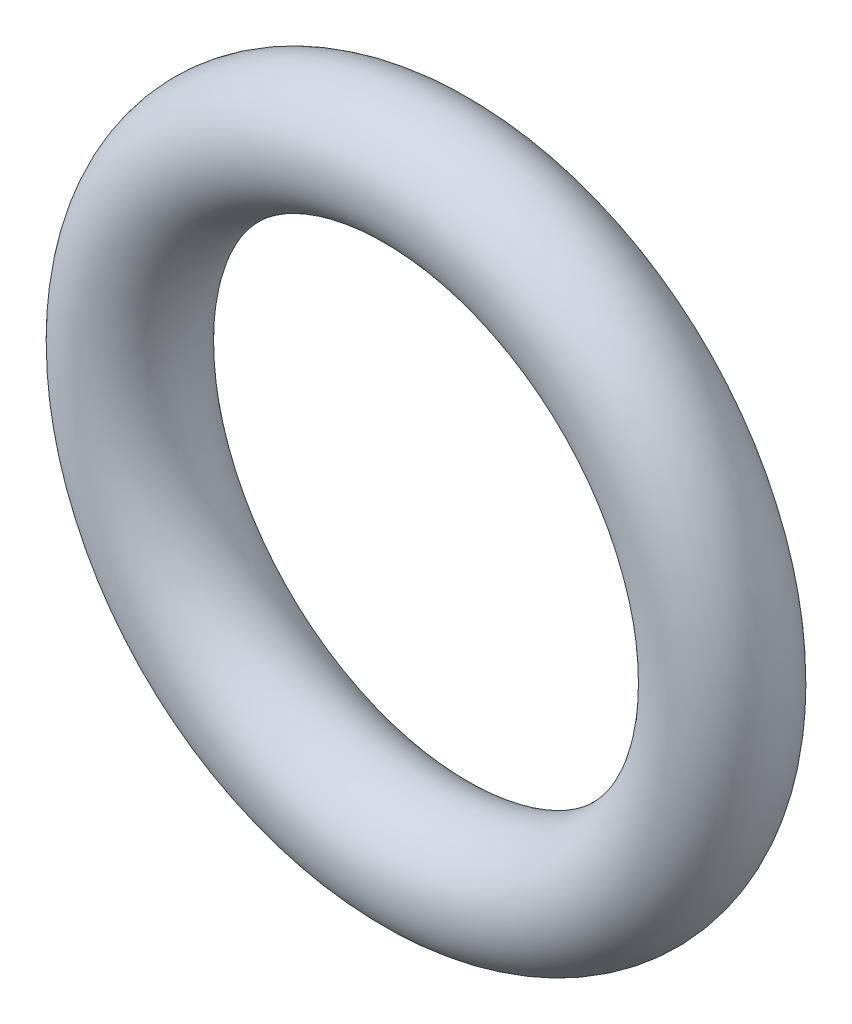
from build123d import *

# Parameters (mm, degrees)
SKETCH2_R = 1.016


with BuildPart() as part:
    # Sweep1: sweep along a path in Sketch1
    with BuildLine(Plane.XY) as sweep1_path:
        CenterArc((0, 0), 5.08, 0, 360)
    # Sketch2 → Sweep1 (sweep)
    with BuildSketch(Plane(origin=(0, 0, 0), x_dir=(1, 0, 0), z_dir=(0, 1, 0))):
        with Locations((5.08, 0)):
            Circle(SKETCH2_R)
    sweep(path=sweep1_path.line)


solid = part.part
